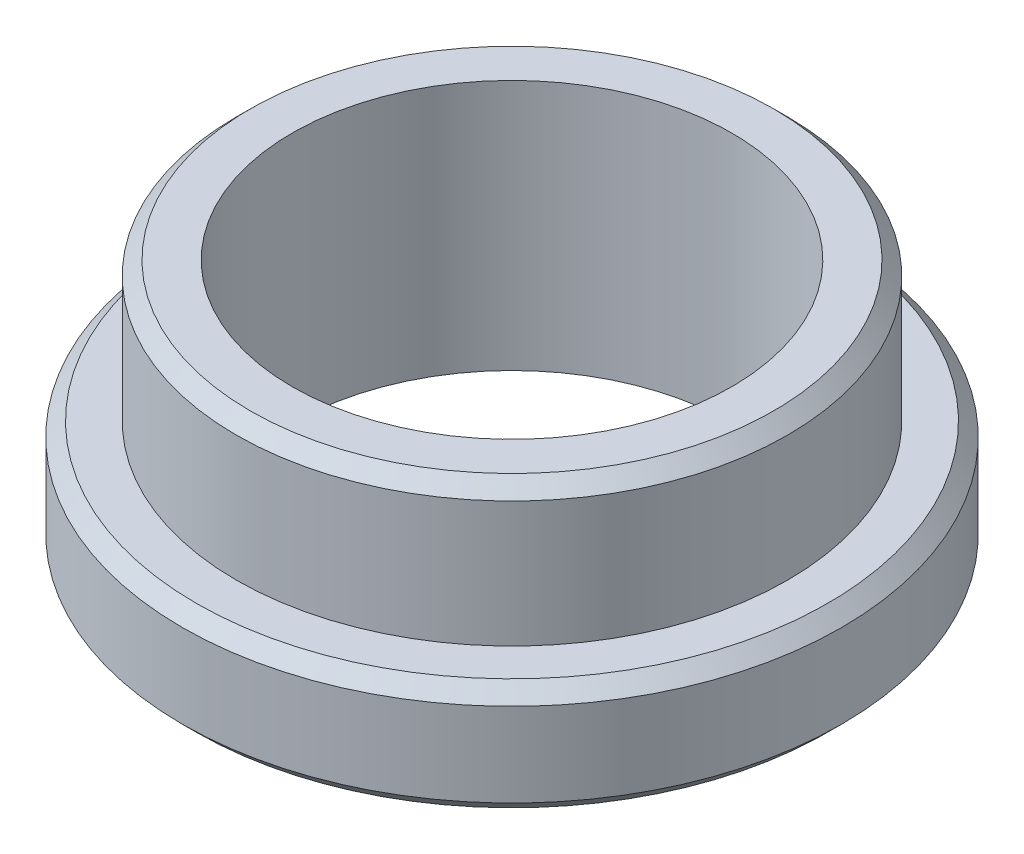
from build123d import *

# Parameters (mm, degrees)
CHAMFER1_SIZE = 0.254


with BuildPart() as part:
    # Sketch1 → Revolve1 (revolve)
    with BuildSketch(Plane.XY):
        Polygon((5.016, 0), (5.016, -2.54), (6, -2.54), (6, -4.572), (4, -4.572), (4, 0), align=None)
    revolve(axis=Axis((0, 0, 0), (0, -1, 0)))

    # Chamfer1
    chamfer1_edges = [part.edges().sort_by_distance(p)[0] for p in [
        (-6, -4.572, 0),
        (-6, -2.54, 0),
        (-5.016, 0, 0),
    ]]
    chamfer(chamfer1_edges, length=CHAMFER1_SIZE)


solid = part.part
